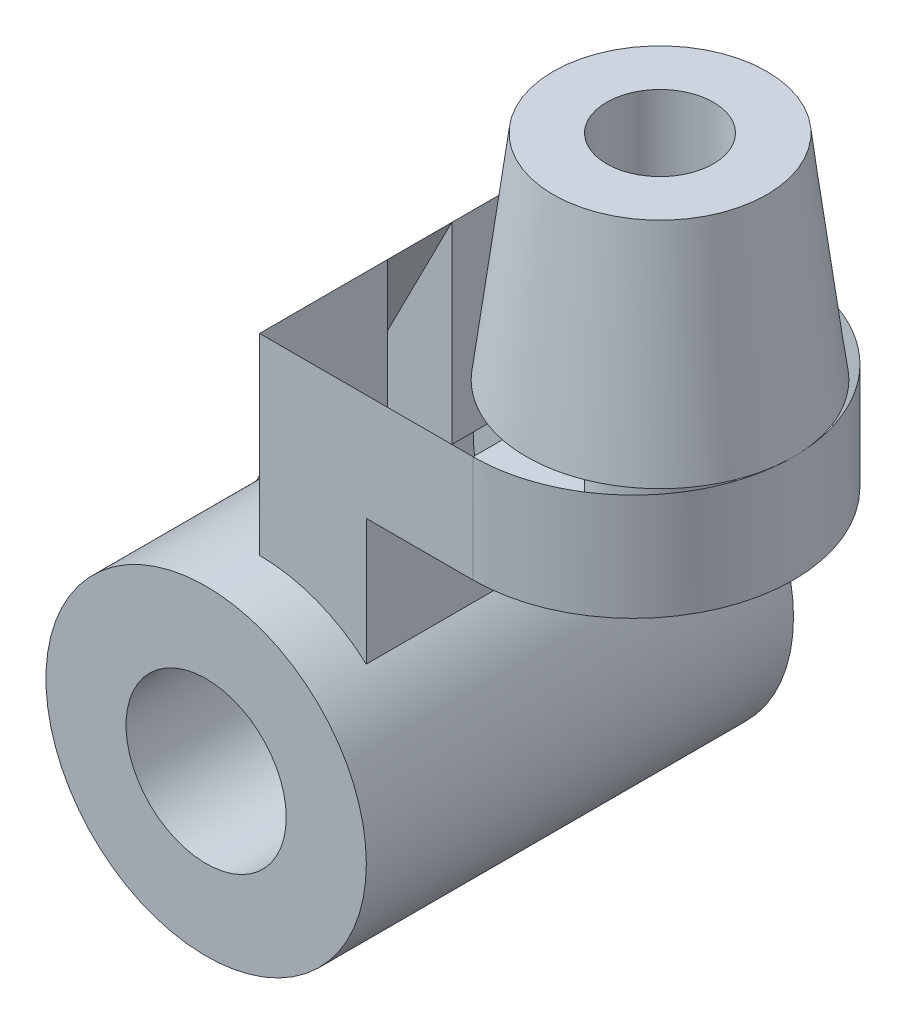
from build123d import *

# Parameters (mm, degrees)
SKETCH1_R           = 30
SKETCH1_R_2         = 15
BOSS_EXTRUDE3_DEPTH = 40
BOSS_EXTRUDE4_DEPTH = 30
BOSS_EXTRUDE5_DEPTH = 20
BOSS_EXTRUDE6_DEPTH = 6
SKETCH11_R          = 10
CUT_EXTRUDE1_DEPTH  = 60


with BuildPart() as part:
    # Sketch1 → Boss-Extrude3 (new body, symmetric)
    with BuildSketch(Plane.XY):
        Circle(SKETCH1_R)
        Circle(SKETCH1_R_2, mode=Mode.SUBTRACT)
    extrude(amount=BOSS_EXTRUDE3_DEPTH, both=True)

    # Sketch4 → Boss-Extrude4 (add, symmetric)
    with BuildSketch(Plane.XY):
        with BuildLine():
            Line((0, 30), (0, 66))
            Line((0, 66), (40, 66))
            Line((40, 66), (40, 46))
            Line((40, 46), (20, 46))
            Line((20, 46), (20, 22.360679775))
            ThreePointArc((20, 22.360679775), (10.704662693, 28.025170769), (0, 30))
        make_face()
    extrude(amount=BOSS_EXTRUDE4_DEPTH, both=True)

    # Sketch5 → Boss-Extrude5 (add)
    with BuildSketch(Plane(origin=(0, 66, 0), x_dir=(1, 0, 0), z_dir=(0, 1, 0))):
        with BuildLine():
            Line((40, 30), (40, -30))
            ThreePointArc((40, -30), (70, 0), (40, 30))
        make_face()
    extrude(amount=-BOSS_EXTRUDE5_DEPTH)

    # Sketch9 → Boss-Extrude6 (add, symmetric)
    with BuildSketch(Plane.XY):
        with BuildLine():
            Line((0, 66), (-26.721706285, 13.636363636))
            ThreePointArc((-26.721706285, 13.636363636), (-15.666989036, 25.584085963), (0, 30))
            Line((0, 30), (0, 66))
        make_face()
    extrude(amount=BOSS_EXTRUDE6_DEPTH, both=True)

    # Sketch10 → Revolve1 (revolve)
    with BuildSketch(Plane.XY, mode=Mode.PRIVATE) as revolve1_sk:
        Polygon((20, 66), (45, 66), (45, 106), (25, 106), align=None)
    revolve(revolve1_sk.sketch.rotate(Axis((45, 66, 0), (0, 1, 0)), 270), axis=Axis((45, 66, 0), (0, 1, 0)))  # turned: the seam where the file's is

    # Sketch11 → Cut-Extrude1 (cut)
    with BuildSketch(Plane(origin=(0, 106, 0), x_dir=(1, 0, 0), z_dir=(0, 1, 0))):
        with Locations(Location((45, 0, 0), (0, 0, 270))):  # turned: the seam where the file's is
            Circle(SKETCH11_R)
    extrude(amount=-CUT_EXTRUDE1_DEPTH, mode=Mode.SUBTRACT)


solid = part.part
